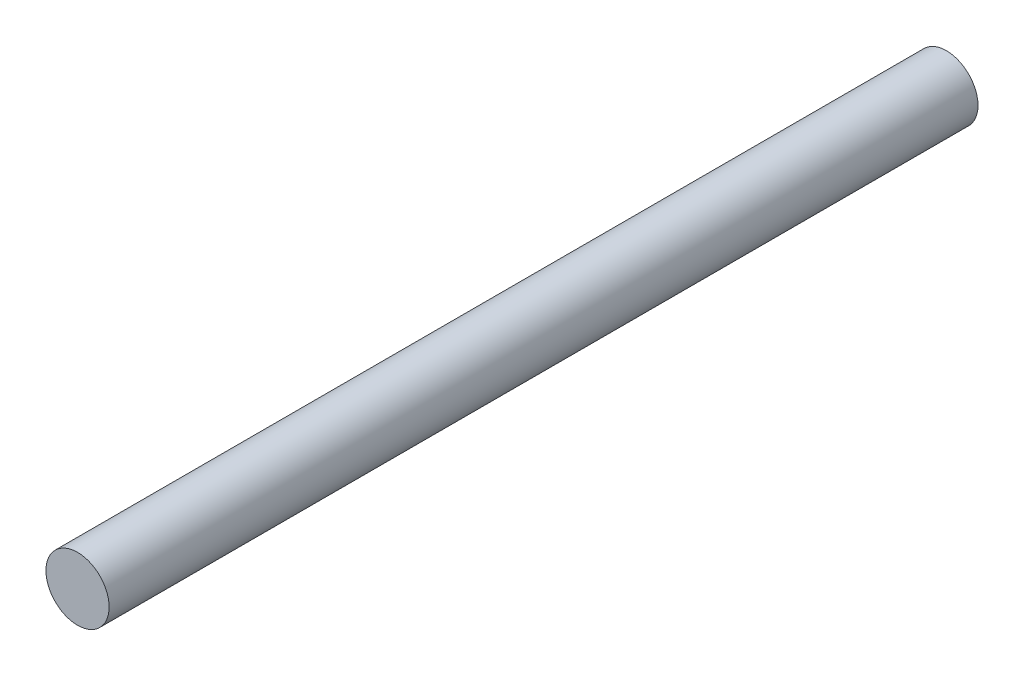
from build123d import *

# Parameters (mm, degrees)
CROQUIS1_R              = 4
SALIENTE_EXTRUIR1_DEPTH = 110


with BuildPart() as part:
    # Croquis1 → Saliente-Extruir1 (new body)
    with BuildSketch(Plane.XY):
        Circle(CROQUIS1_R)
    extrude(amount=SALIENTE_EXTRUIR1_DEPTH)


solid = part.part
